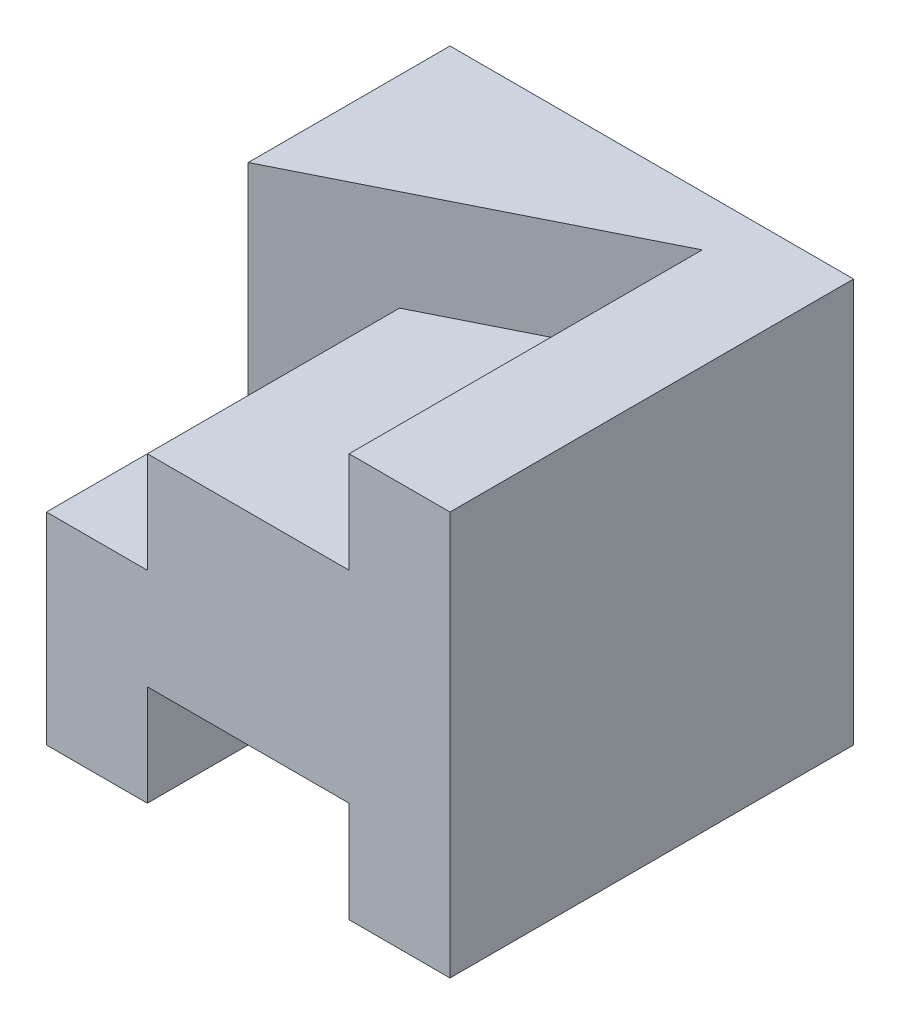
from build123d import *

# Parameters (mm, degrees)
BOSS_EXTRUDE1_DEPTH = 4
BOSS_EXTRUDE4_DEPTH = 2


with BuildPart() as part:
    # Sketch1 → Boss-Extrude1 (new body)
    with BuildSketch(Plane.XY):
        Polygon((0, 0), (0, 2), (1, 2), (1, 3), (3, 3), (3, 4), (4, 4), (4, 0), (3, 0), (3, 1), (1, 1), (1, 0), align=None)
    extrude(amount=BOSS_EXTRUDE1_DEPTH)

    # Sketch6 → Boss-Extrude4 (add)
    with BuildSketch(Plane(origin=(0, 4, 0), x_dir=(1, 0, 0), z_dir=(0, 1, 0))):
        Polygon((4, 0), (0, -2), (0, 0), align=None)
    extrude(amount=-BOSS_EXTRUDE4_DEPTH)


solid = part.part
